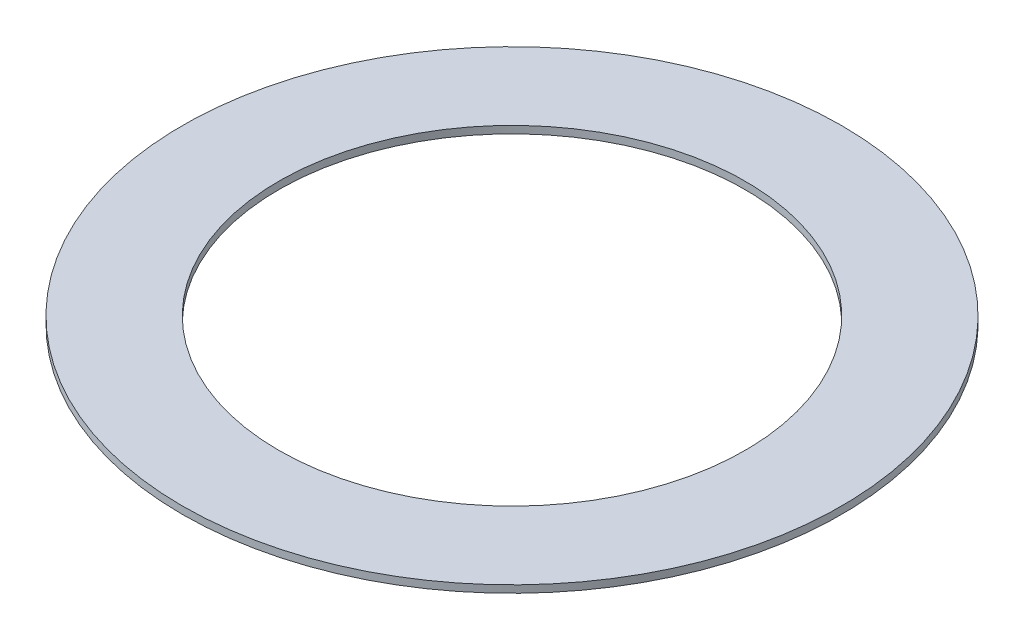
from build123d import *

# Parameters (mm, degrees)
SKETCH1_R           = 107.696
SKETCH1_R_2         = 76.2
BOSS_EXTRUDE1_DEPTH = 2.4


with BuildPart() as part:
    # Sketch1 → Boss-Extrude1 (new body)
    with BuildSketch(Plane(origin=(0, 0, 0), x_dir=(1, 0, 0), z_dir=(0, 1, 0))):
        Circle(SKETCH1_R)
        Circle(SKETCH1_R_2, mode=Mode.SUBTRACT)
    extrude(amount=BOSS_EXTRUDE1_DEPTH)


solid = part.part
